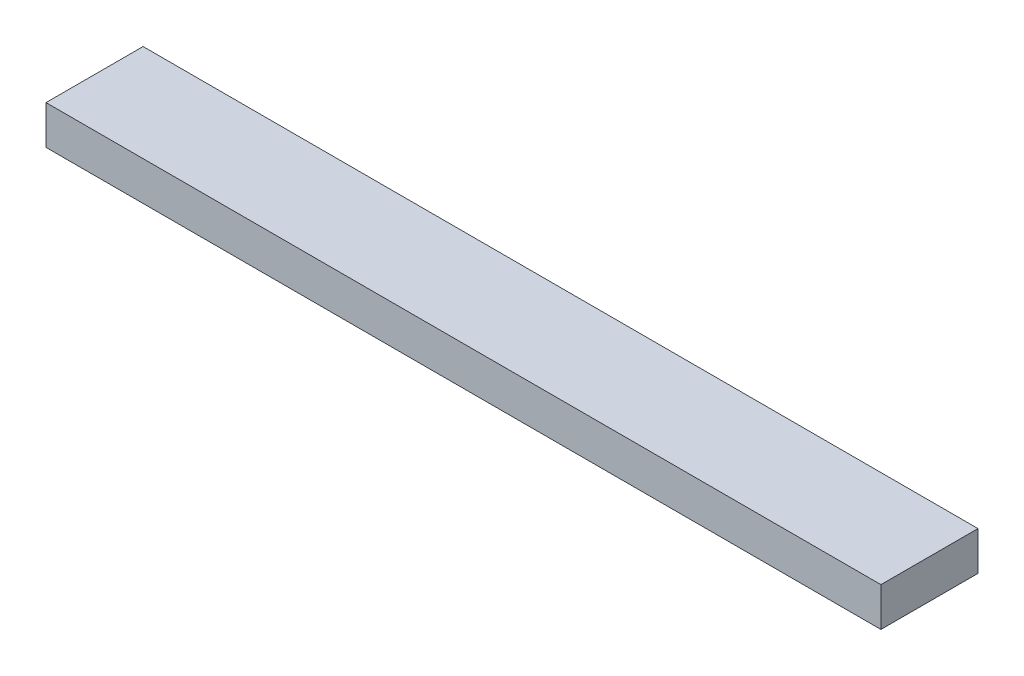
from build123d import *

# Parameters (mm, degrees)
SKETCH1_W           = 127
SKETCH1_H           = 50.8
BOSS_EXTRUDE1_DEPTH = 1092.2


with BuildPart() as part:
    # Sketch1 → Boss-Extrude1 (new body)
    with BuildSketch(Plane(origin=(0, 0, 0), x_dir=(0, 0, -1), z_dir=(1, 0, 0))):
        with Locations((63.5, 25.4)):
            Rectangle(SKETCH1_W, SKETCH1_H)
    extrude(amount=BOSS_EXTRUDE1_DEPTH)


solid = part.part
